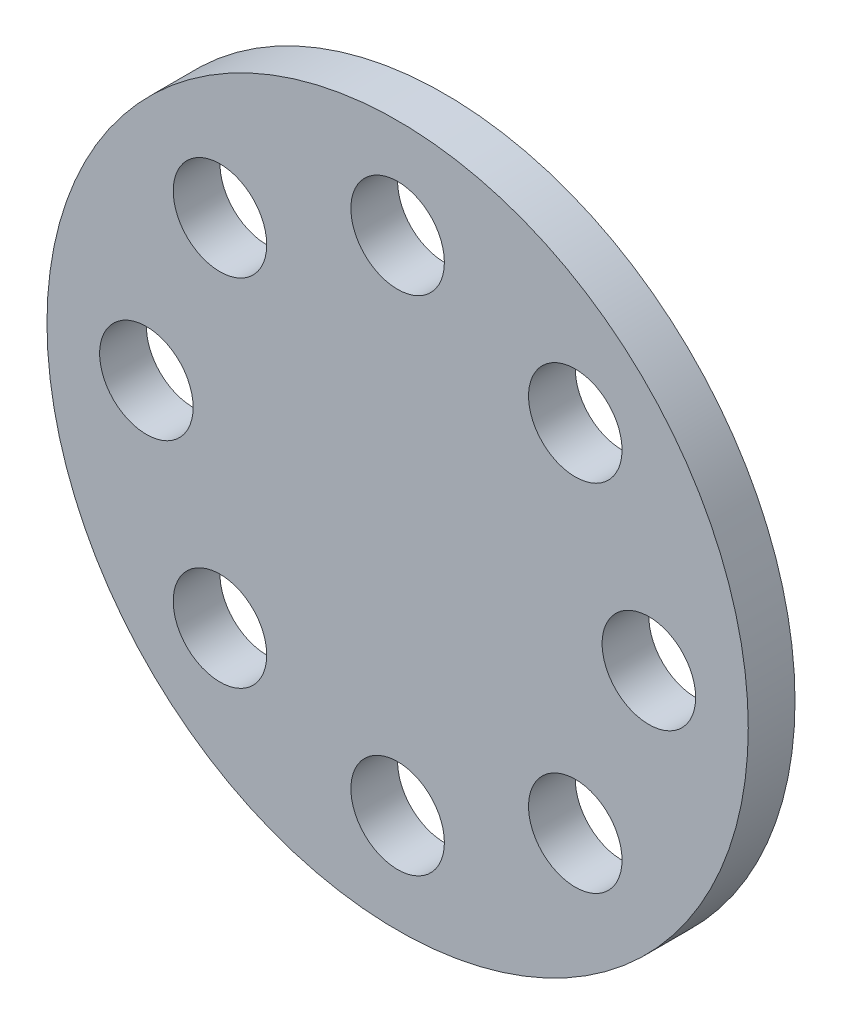
from build123d import *

# Parameters (mm, degrees)
SKETCH1_R           = 75
SKETCH1_R_2         = 10
BOSS_EXTRUDE1_DEPTH = 10


with BuildPart() as part:
    # Sketch1 → Boss-Extrude1 (new body)
    with BuildSketch(Plane.XY):
        Circle(SKETCH1_R)
        with Locations((0, 53.737864078)):
            Circle(SKETCH1_R_2, mode=Mode.SUBTRACT)
        with Locations((37.998408096, 37.998408096)):
            Circle(SKETCH1_R_2, mode=Mode.SUBTRACT)
        with Locations((53.737864078, 0)):
            Circle(SKETCH1_R_2, mode=Mode.SUBTRACT)
        with Locations((37.998408096, -37.998408096)):
            Circle(SKETCH1_R_2, mode=Mode.SUBTRACT)
        with Locations((0, -53.737864078)):
            Circle(SKETCH1_R_2, mode=Mode.SUBTRACT)
        with Locations((-37.998408096, -37.998408096)):
            Circle(SKETCH1_R_2, mode=Mode.SUBTRACT)
        with Locations((-53.737864078, 0)):
            Circle(SKETCH1_R_2, mode=Mode.SUBTRACT)
        with Locations((-37.998408096, 37.998408096)):
            Circle(SKETCH1_R_2, mode=Mode.SUBTRACT)
    extrude(amount=BOSS_EXTRUDE1_DEPTH)


solid = part.part
